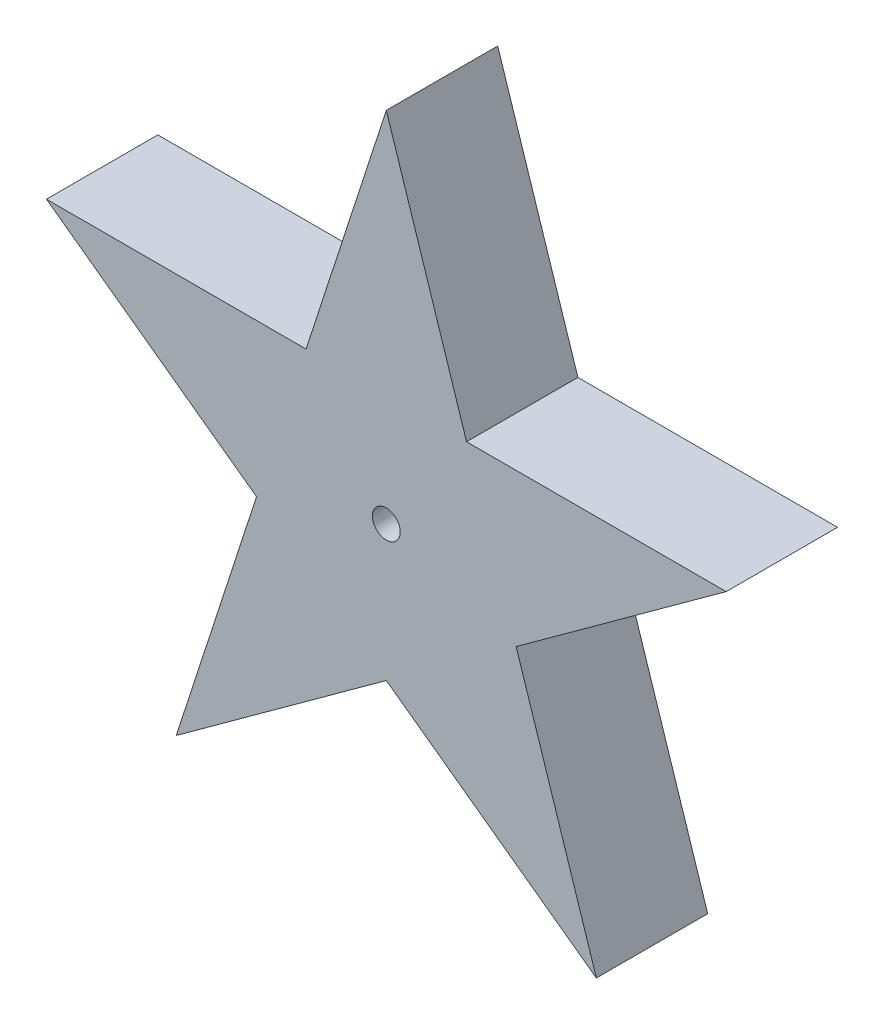
from build123d import *

# Parameters (mm, degrees)
BOSS_EXTRU_1_DEPTH      = 1
ESQUISSE4_R             = 0.125
ENL_V_MAT_EXTRU_1_DEPTH = 2


with BuildPart() as part:
    # Esquisse3 → Boss.-Extru.1 (new body)
    with BuildSketch(Plane.XY):
        Polygon((0, 3.217227712), (0.720420955, 1), (3.051752136, 1), (1.165665591, -0.370322087), (1.886086545, -2.587549798), (0, -1.217227712), (-1.886086545, -2.587549798), (-1.165665591, -0.370322087), (-3.051752136, 1), (-0.720420955, 1), align=None)
    extrude(amount=BOSS_EXTRU_1_DEPTH)

    # Esquisse4 → Enlèv. mat.-Extru.1 (cut, through all)
    with BuildSketch(Plane(origin=(0, 0, 0), x_dir=(-1, 0, 0), z_dir=(0, 0, -1))):
        Circle(ESQUISSE4_R)
    extrude(amount=-ENL_V_MAT_EXTRU_1_DEPTH, mode=Mode.SUBTRACT)


solid = part.part
